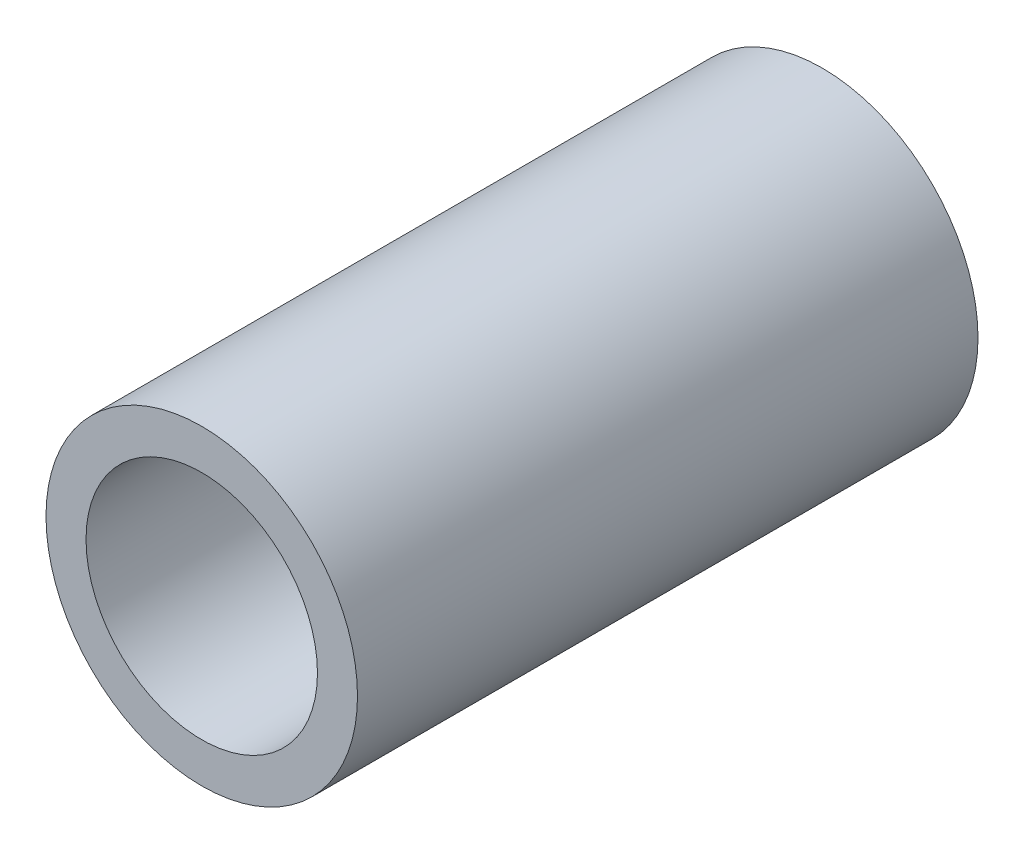
from build123d import *

# Parameters (mm, degrees)
SKETCH1_R      = 3.1877
SKETCH1_R_2    = 2.36855
EXTRUDE1_DEPTH = 6.35


with BuildPart() as part:
    # Sketch1 → Extrude1 (new body, symmetric)
    with BuildSketch(Plane.XY):
        Circle(SKETCH1_R)
        Circle(SKETCH1_R_2, mode=Mode.SUBTRACT)
    extrude(amount=EXTRUDE1_DEPTH, both=True)


solid = part.part
